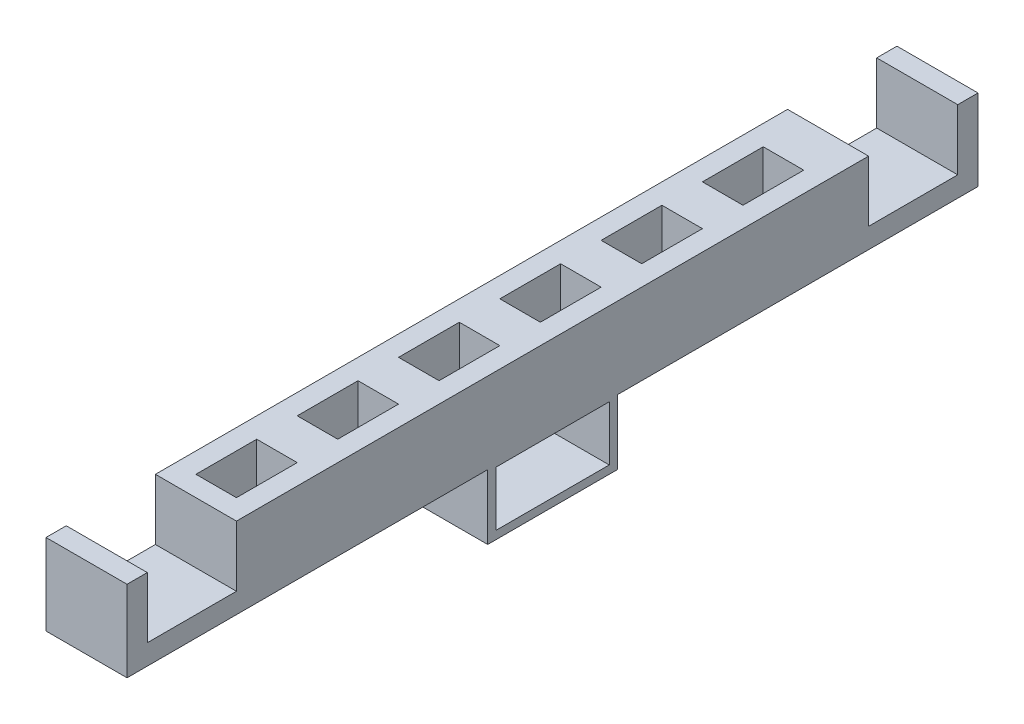
from build123d import *

# Parameters (mm, degrees)
SKETCH1_W           = 20
SKETCH1_H           = 210
BOSS_EXTRUDE1_DEPTH = 20
SKETCH2_W           = 20
SKETCH2_H           = 22
CUT_EXTRUDE1_DEPTH  = 15
SKETCH3_W           = 20
SKETCH3_H           = 22
CUT_EXTRUDE2_DEPTH  = 15
SKETCH4_W           = 10
SKETCH4_H           = 15
CUT_EXTRUDE3_DEPTH  = 21
SKETCH5_W           = 20
SKETCH5_H           = 32
BOSS_EXTRUDE2_DEPTH = 16
SKETCH6_W           = 28
SKETCH6_H           = 13.5
CUT_EXTRUDE4_DEPTH  = 21


with BuildPart() as part:
    # Sketch1 → Boss-Extrude1 (new body)
    with BuildSketch(Plane(origin=(0, 0, 0), x_dir=(1, 0, 0), z_dir=(0, 1, 0))):
        with Locations((10, 105)):
            Rectangle(SKETCH1_W, SKETCH1_H)
    extrude(amount=BOSS_EXTRUDE1_DEPTH)

    # Sketch2 → Cut-Extrude1 (cut)
    with BuildSketch(Plane(origin=(0, 20, 0), x_dir=(1, 0, 0), z_dir=(0, 1, 0))):
        with Locations((10, 16)):
            Rectangle(SKETCH2_W, SKETCH2_H)
    extrude(amount=-CUT_EXTRUDE1_DEPTH, mode=Mode.SUBTRACT)

    # Sketch3 → Cut-Extrude2 (cut)
    with BuildSketch(Plane(origin=(0, 20, 0), x_dir=(1, 0, 0), z_dir=(0, 1, 0))):
        with Locations((10, 194)):
            Rectangle(SKETCH3_W, SKETCH3_H)
    extrude(amount=-CUT_EXTRUDE2_DEPTH, mode=Mode.SUBTRACT)

    # Sketch4 → Cut-Extrude3 (cut, through all)
    with BuildSketch(Plane(origin=(0, 20, 0), x_dir=(1, 0, 0), z_dir=(0, 1, 0))):
        with Locations((10, 39.5)):
            Rectangle(SKETCH4_W, SKETCH4_H)
        with Locations((10, 64.5)):
            Rectangle(SKETCH4_W, SKETCH4_H)
        with Locations((10, 89.5)):
            Rectangle(SKETCH4_W, SKETCH4_H)
        with Locations((10, 114.5)):
            Rectangle(SKETCH4_W, SKETCH4_H)
        with Locations((10, 139.5)):
            Rectangle(SKETCH4_W, SKETCH4_H)
        with Locations((10, 164.5)):
            Rectangle(SKETCH4_W, SKETCH4_H)
    extrude(amount=-CUT_EXTRUDE3_DEPTH, mode=Mode.SUBTRACT)

    # Sketch5 → Boss-Extrude2 (add)
    with BuildSketch(Plane(origin=(0, 0, 0), x_dir=(-1, 0, 0), z_dir=(0, -1, 0))):
        with Locations((-10, 105)):
            Rectangle(SKETCH5_W, SKETCH5_H)
    extrude(amount=BOSS_EXTRUDE2_DEPTH)

    # Sketch6 → Cut-Extrude4 (cut, through all)
    with BuildSketch(Plane(origin=(20, 0, 0), x_dir=(0, 0, -1), z_dir=(1, 0, 0))):
        with Locations((105, -7.25)):
            Rectangle(SKETCH6_W, SKETCH6_H)
    extrude(amount=-CUT_EXTRUDE4_DEPTH, mode=Mode.SUBTRACT)


solid = part.part
